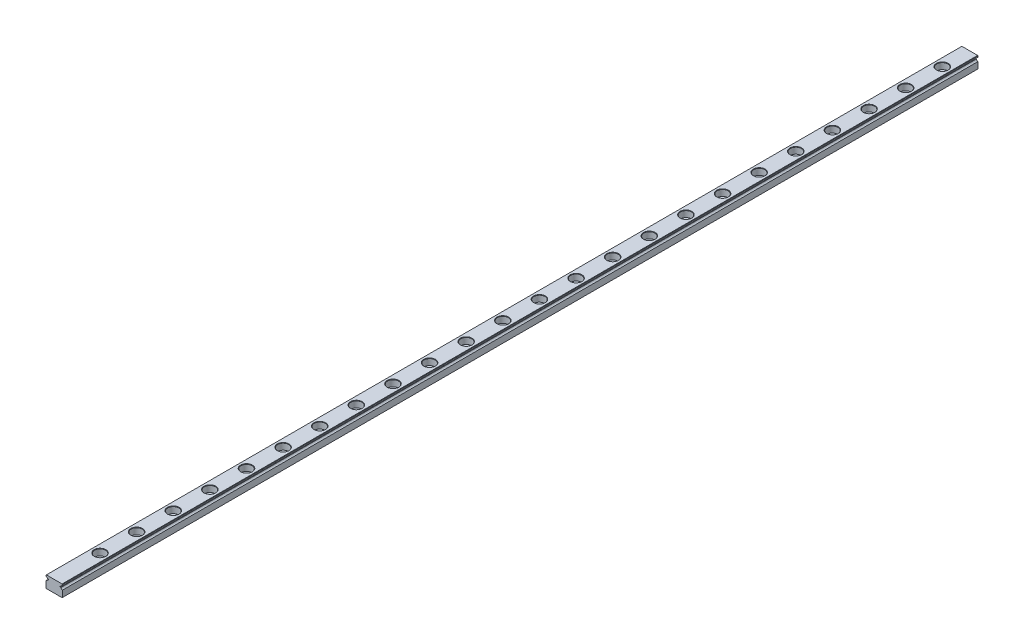
from build123d import *

# Parameters (mm, degrees)
EXTRUDE1_DEPTH             = 500
EXTRUDE2_REACH             = 502.062
SKETCH2_R                  = 1.75
SKETCH_R                   = 3
SKETCH_R_2                 = 1.75
EXTRUDE4_DEPTH             = 3.5
CHAMFER1_SIZE              = 0.2
LPATTERN1_COUNT            = 24
LPATTERN1_PITCH            = 20
CHAMFER1_OF_LPATTERN1_SIZE = 0.2


with BuildPart() as part:
    # Sketch1 → Extrude1 (new body)
    with BuildSketch(Plane.XY):
        with BuildLine():
            Line((-4.3, -3.25), (4.3, -3.25))
            Line((4.3, -3.25), (4.5, -3.05))
            Line((4.5, -3.05), (4.5, 0.455012563))
            ThreePointArc((4.5, 0.455012563), (3.924845827, 0.712323349), (3.617735397, 1.2625))
            Line((3.617735397, 1.2625), (3.15008224, 1.2625))
            Line((3.15008224, 1.2625), (3.15008224, 1.7625))
            Line((3.15008224, 1.7625), (3.65008224, 1.7625))
            ThreePointArc((3.65008224, 1.7625), (3.973877727, 2.229724887), (4.5, 2.444987437))
            Line((4.5, 2.444987437), (4.5, 3.05))
            Line((4.5, 3.05), (4.3, 3.25))
            Line((4.3, 3.25), (-4.3, 3.25))
            Line((-4.3, 3.25), (-4.5, 3.05))
            Line((-4.5, 3.05), (-4.5, 2.444987437))
            ThreePointArc((-4.5, 2.444987437), (-3.973877727, 2.229724887), (-3.65008224, 1.7625))
            Line((-3.65008224, 1.7625), (-3.15008224, 1.7625))
            Line((-3.15008224, 1.7625), (-3.15008224, 1.2625))
            Line((-3.15008224, 1.2625), (-3.617735397, 1.2625))
            ThreePointArc((-3.617735397, 1.2625), (-3.924845827, 0.712323349), (-4.5, 0.455012563))
            Line((-4.5, 0.455012563), (-4.5, -3.05))
            Line((-4.5, -3.05), (-4.3, -3.25))
        make_face()
    extrude(amount=EXTRUDE1_DEPTH)

    # Sketch2 → Extrude2 (cut, up to next)
    with BuildSketch(Plane(origin=(0, 3.25, 0), x_dir=(1, 0, 0), z_dir=(0, 1, 0)), mode=Mode.PRIVATE) as extrude2_sk1:
        with Locations((0, -15)):
            Circle(SKETCH2_R)
    extrude2_tool1 = extrude(extrude2_sk1.sketch, amount=-EXTRUDE2_REACH, mode=Mode.PRIVATE) & part.part
    extrude2 = extrude2_tool1.solids().sort_by_distance((0, 3.25, 15))[0]
    add(extrude2, mode=Mode.SUBTRACT)

    # Sketch → Extrude4 (cut)
    with BuildSketch(Plane(origin=(0, 3.25, 0), x_dir=(1, 0, 0), z_dir=(0, 1, 0))):
        with Locations((0, -15)):
            Circle(SKETCH_R)
        with Locations((0, -15)):
            Circle(SKETCH_R_2, mode=Mode.SUBTRACT)
    extrude4 = extrude(amount=-EXTRUDE4_DEPTH, mode=Mode.SUBTRACT)

    # Chamfer1
    chamfer1_edges = [part.edges().sort_by_distance(p)[0] for p in [
        (-1.75, -3.25, 15),
        (-3, 3.25, 15),
    ]]
    chamfer(chamfer1_edges, length=CHAMFER1_SIZE)

    # LPattern1: Extrude2, Extrude4 ×24
    with Locations(*[(0, 0, i * LPATTERN1_PITCH) for i in range(1, LPATTERN1_COUNT)]):
        add(extrude2, mode=Mode.SUBTRACT)
        add(extrude4, mode=Mode.SUBTRACT)

    # Chamfer1 of LPattern1
    chamfer1_of_lpattern1_edges = [part.edges().sort_by_distance(p)[0] for p in [
        (-1.75, -3.25, 35),
        (-3, 3.25, 35),
        (-1.75, -3.25, 55),
        (-3, 3.25, 55),
        (-1.75, -3.25, 75),
        (-3, 3.25, 75),
        (-1.75, -3.25, 95),
        (-3, 3.25, 95),
        (-1.75, -3.25, 115),
        (-3, 3.25, 115),
        (-1.75, -3.25, 135),
        (-3, 3.25, 135),
        (-1.75, -3.25, 155),
        (-3, 3.25, 155),
        (-1.75, -3.25, 175),
        (-3, 3.25, 175),
        (-1.75, -3.25, 195),
        (-3, 3.25, 195),
        (-1.75, -3.25, 215),
        (-3, 3.25, 215),
        (-1.75, -3.25, 235),
        (-3, 3.25, 235),
        (-1.75, -3.25, 255),
        (-3, 3.25, 255),
        (-1.75, -3.25, 275),
        (-3, 3.25, 275),
        (-1.75, -3.25, 295),
        (-3, 3.25, 295),
        (-1.75, -3.25, 315),
        (-3, 3.25, 315),
        (-1.75, -3.25, 335),
        (-3, 3.25, 335),
        (-1.75, -3.25, 355),
        (-3, 3.25, 355),
        (-1.75, -3.25, 375),
        (-3, 3.25, 375),
        (-1.75, -3.25, 395),
        (-3, 3.25, 395),
        (-1.75, -3.25, 415),
        (-3, 3.25, 415),
        (-1.75, -3.25, 435),
        (-3, 3.25, 435),
        (-1.75, -3.25, 455),
        (-3, 3.25, 455),
        (-1.75, -3.25, 475),
        (-3, 3.25, 475),
    ]]
    chamfer(chamfer1_of_lpattern1_edges, length=CHAMFER1_OF_LPATTERN1_SIZE)


solid = part.part
